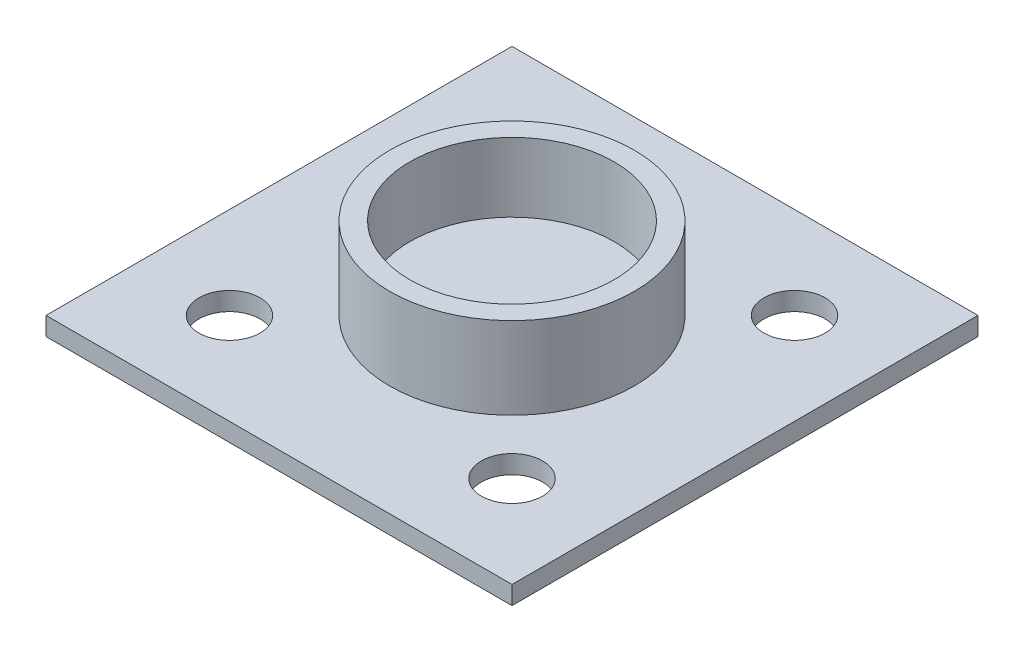
from build123d import *

# Parameters (mm, degrees)
ESQUISSE1_R             = 10
BOSS_EXTRU_1_DEPTH      = 8.2
ESQUISSE2_R             = 8.354
ENL_V_MAT_EXTRU_1_DEPTH = 5.65
ESQUISSE3_W             = 38.1
ESQUISSE3_H             = 38.1
BOSS_EXTRU_3_DEPTH      = 1.5
ESQUISSE4_R             = 2.5
ENL_V_MAT_EXTRU_2_DEPTH = 2


with BuildPart() as part:
    # Esquisse1 → Boss.-Extru.1 (new body)
    with BuildSketch(Plane(origin=(0, 0, 0), x_dir=(1, 0, 0), z_dir=(0, 1, 0))):
        Circle(ESQUISSE1_R)
    extrude(amount=-BOSS_EXTRU_1_DEPTH)

    # Esquisse2 → Enlèv. mat.-Extru.1 (cut)
    with BuildSketch(Plane(origin=(0, 0, 0), x_dir=(1, 0, 0), z_dir=(0, 1, 0))):
        Circle(ESQUISSE2_R)
    extrude(amount=-ENL_V_MAT_EXTRU_1_DEPTH, mode=Mode.SUBTRACT)

    # Esquisse3 → Boss.-Extru.3 (add)
    with BuildSketch(Plane(origin=(0, -8.2, 0), x_dir=(-1, 0, 0), z_dir=(0, -1, 0))):
        Rectangle(ESQUISSE3_W, ESQUISSE3_H)
    extrude(amount=-BOSS_EXTRU_3_DEPTH)

    # Esquisse4 → Enlèv. mat.-Extru.2 (cut)
    with BuildSketch(Plane(origin=(0, -6.7, 0), x_dir=(1, 0, 0), z_dir=(0, 1, 0))):
        with Locations((-11.55, 11.55)):
            Circle(ESQUISSE4_R)
        with Locations((11.55, 11.55)):
            Circle(ESQUISSE4_R)
        with Locations((11.55, -11.55)):
            Circle(ESQUISSE4_R)
        with Locations((-11.55, -11.55)):
            Circle(ESQUISSE4_R)
    extrude(amount=-ENL_V_MAT_EXTRU_2_DEPTH, mode=Mode.SUBTRACT)


solid = part.part
